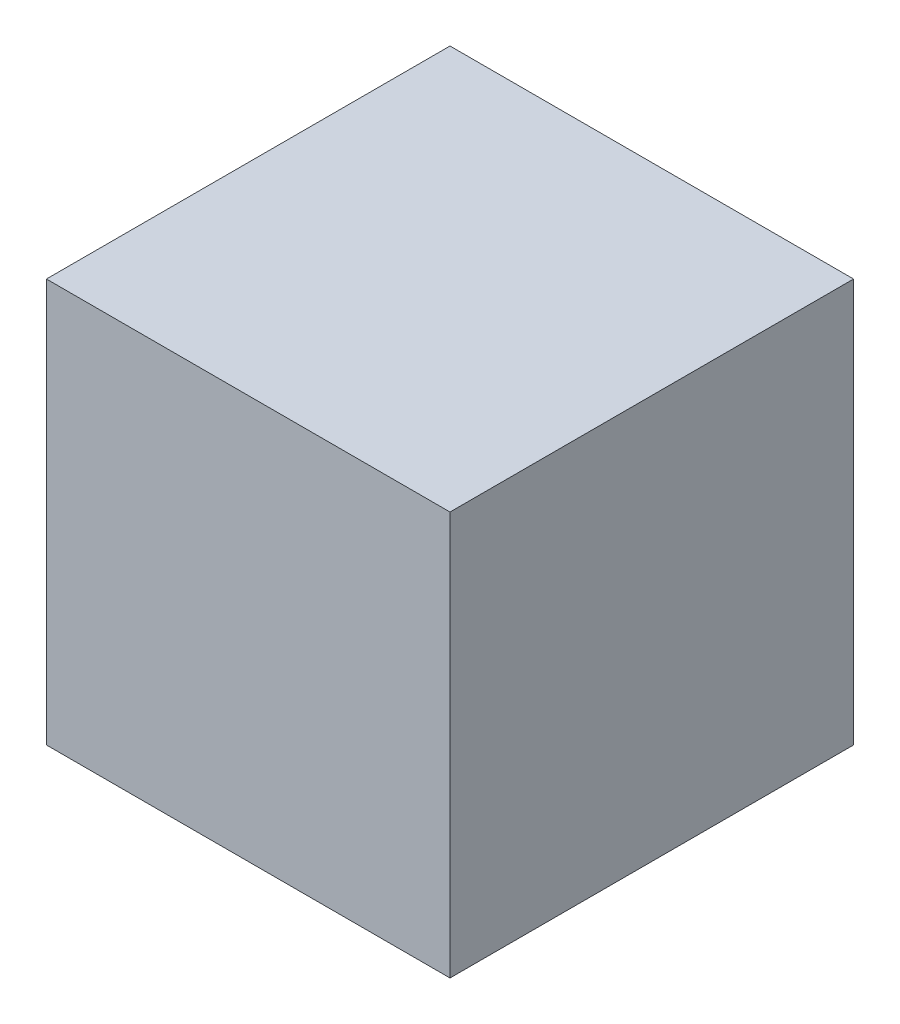
from build123d import *

# Parameters (mm, degrees)
SKETCH3_W            = 10
SKETCH3_H            = 10
ALIGNMENT_CUBE_DEPTH = 10


with BuildPart() as part:
    # Sketch3 → alignment Cube (new body)
    with BuildSketch(Plane(origin=(0, 60, 0), x_dir=(1, 0, 0), z_dir=(0, 1, 0))):
        with Locations((-5, -5)):
            Rectangle(SKETCH3_W, SKETCH3_H)
    extrude(amount=-ALIGNMENT_CUBE_DEPTH)


solid = part.part
